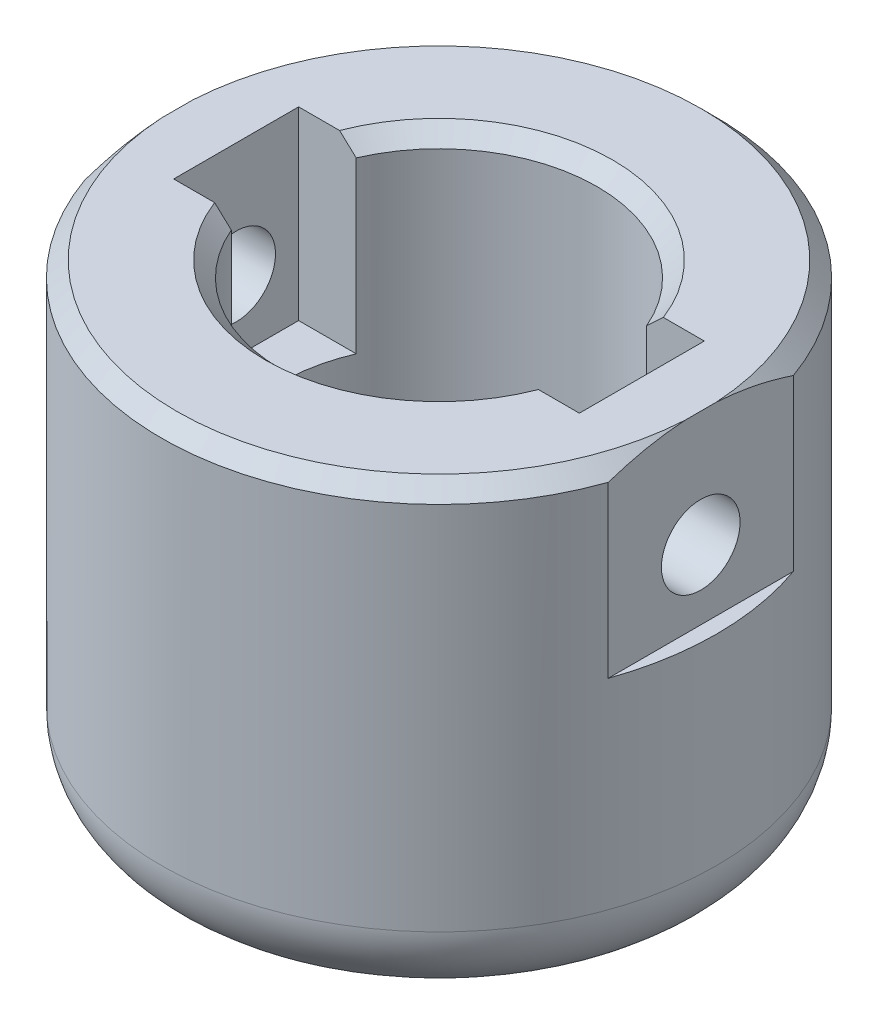
from build123d import *

# Parameters (mm, degrees)
FILLET1_R               = 1
CHAMFER1_SIZE           = 1
FILLET2_R               = 5
SKETCH3_W               = 2
SKETCH3_H               = 12
CUT_EXTRUDE1_DEPTH      = 12
SKETCH4_R               = 2.55
CUT_EXTRUDE2_DEPTH      = 19
CUT_EXTRUDE2_DEPTH_BACK = 19


with BuildPart() as part:
    # Sketch1 → Revolve1 (revolve)
    with BuildSketch(Plane.XY):
        Polygon((18, 0), (5.25, 0), (5.25, 3), (10.25, 3), (10.25, 30), (18, 30), align=None)
    revolve(axis=Axis((0, -427.095192794, 0), (0, 1, 0)))

    # Fillet1
    fillet1_edges = [part.edges().sort_by_distance(p)[0] for p in [
        (-10.25, 3, 0),
    ]]
    fillet(fillet1_edges, radius=FILLET1_R)

    # Chamfer1
    chamfer1_edges = [part.edges().sort_by_distance(p)[0] for p in [
        (-18, 30, 0),
        (-10.25, 30, 0),
    ]]
    chamfer(chamfer1_edges, length=CHAMFER1_SIZE)

    # Fillet2
    fillet2_edges = [part.edges().sort_by_distance(p)[0] for p in [
        (-18, 0, 0),
    ]]
    fillet(fillet2_edges, radius=FILLET2_R)

    # Sketch3 → Cut-Extrude1 (cut)
    with BuildSketch(Plane(origin=(0, 30, 0), x_dir=(1, 0, 0), z_dir=(0, 1, 0))):
        with BuildLine():
            Line((-13.15, 4.05), (-9.415943925, 4.05))
            ThreePointArc((-9.415943925, 4.05), (-10.25, 0), (-9.415943925, -4.05))
            Line((-9.415943925, -4.05), (-13.15, -4.05))
            Line((-13.15, -4.05), (-13.15, 4.05))
        make_face()
        with BuildLine():
            Line((13.15, -4.05), (13.15, 4.05))
            Line((13.15, 4.05), (9.415943925, 4.05))
            ThreePointArc((9.415943925, 4.05), (10.25, 0), (9.415943925, -4.05))
            Line((9.415943925, -4.05), (13.15, -4.05))
        make_face()
        with Locations((17.970562748, 0)):
            Rectangle(SKETCH3_W, SKETCH3_H)
        with Locations((-17.970562748, 0)):
            Rectangle(SKETCH3_W, SKETCH3_H)
    extrude(amount=-CUT_EXTRUDE1_DEPTH, mode=Mode.SUBTRACT)

    # Sketch4 → Cut-Extrude2 (cut, two sides)
    with BuildSketch(Plane(origin=(0, 0, 0), x_dir=(0, 0, -1), z_dir=(1, 0, 0))) as cut_extrude2_sk:
        with Locations((0, 22.5)):
            Circle(SKETCH4_R)
    extrude(amount=CUT_EXTRUDE2_DEPTH, mode=Mode.SUBTRACT)
    extrude(cut_extrude2_sk.sketch, amount=-CUT_EXTRUDE2_DEPTH_BACK, mode=Mode.SUBTRACT)


solid = part.part
